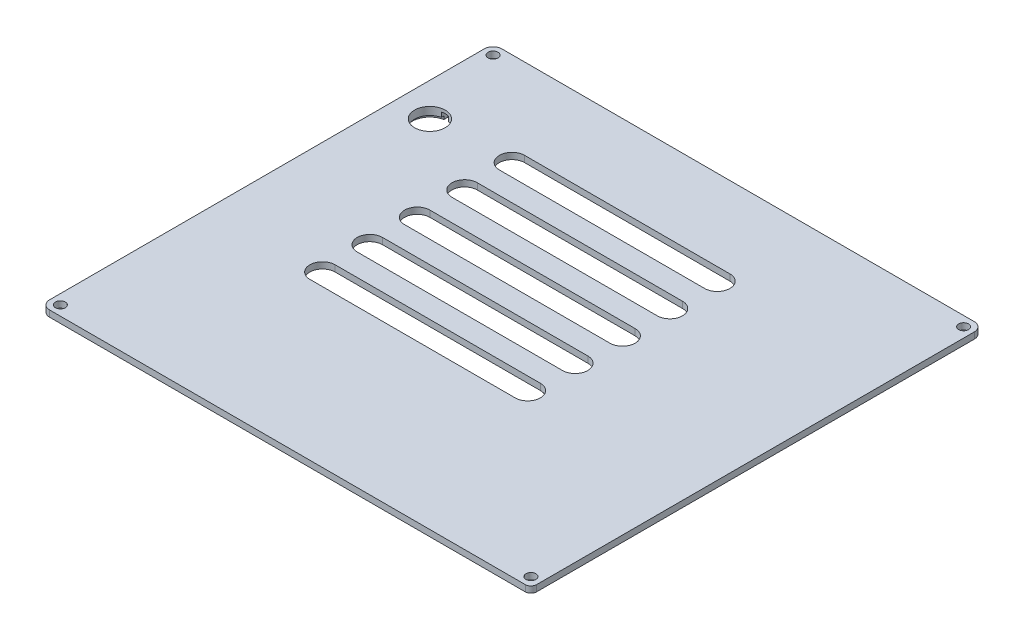
from build123d import *

# Parameters (mm, degrees)
SKETCH1_W           = 156
SKETCH1_H           = 144
BOSS_EXTRUDE1_DEPTH = 2
SKETCH2_R           = 1.575
CUT_EXTRUDE1_DEPTH  = 5
SKETCH3_R           = 4.85
CUT_EXTRUDE2_DEPTH  = 50
SKETCH4_W           = 156
SKETCH4_H           = 144
SKETCH4_W_2         = 155.6
SKETCH4_H_2         = 143.6
CUT_EXTRUDE3_DEPTH  = 50
FILLET1_R           = 3
FILLET2_R           = 2
SKETCH5_R           = 9
SKETCH5_R_2         = 4.85
BOSS_EXTRUDE2_DEPTH = 0.5
SKETCH6_R           = 9
SKETCH6_R_2         = 5.65
BOSS_EXTRUDE3_DEPTH = 1
SKETCH7_W           = 2.2
SKETCH7_H           = 2.3
CUT_EXTRUDE4_DEPTH  = 2.5
CUT_EXTRUDE5_DEPTH  = 10


with BuildPart() as part:
    # Sketch1 → Boss-Extrude1 (new body)
    with BuildSketch(Plane(origin=(0, 0, 0), x_dir=(1, 0, 0), z_dir=(0, 1, 0))):
        with Locations((78, -72)):
            Rectangle(SKETCH1_W, SKETCH1_H)
    extrude(amount=BOSS_EXTRUDE1_DEPTH)

    # Sketch2 → Cut-Extrude1 (cut)
    with BuildSketch(Plane(origin=(0, 2, 0), x_dir=(1, 0, 0), z_dir=(0, 1, 0))):
        with Locations((3.5, -3.5)):
            Circle(SKETCH2_R)
        with Locations((152.5, -3.5)):
            Circle(SKETCH2_R)
        with Locations((152.5, -140.5)):
            Circle(SKETCH2_R)
        with Locations((3.5, -140.5)):
            Circle(SKETCH2_R)
    extrude(amount=-CUT_EXTRUDE1_DEPTH, mode=Mode.SUBTRACT)

    # Sketch3 → Cut-Extrude2 (cut)
    with BuildSketch(Plane(origin=(0, 2, 0), x_dir=(1, 0, 0), z_dir=(0, 1, 0))):
        with Locations((11, -31)):
            Circle(SKETCH3_R)
        with BuildLine():
            Line((36, -26), (101, -26))
            ThreePointArc((101, -26), (105, -30), (101, -34))
            Line((101, -34), (36, -34))
            ThreePointArc((36, -34), (32, -30), (36, -26))
        make_face()
        with BuildLine():
            Line((36, -41), (101, -41))
            ThreePointArc((101, -41), (105, -45), (101, -49))
            Line((101, -49), (36, -49))
            ThreePointArc((36, -49), (32, -45), (36, -41))
        make_face()
        with BuildLine():
            Line((36, -56), (101, -56))
            ThreePointArc((101, -56), (105, -60), (101, -64))
            Line((101, -64), (36, -64))
            ThreePointArc((36, -64), (32, -60), (36, -56))
        make_face()
        with BuildLine():
            Line((36, -71), (101, -71))
            ThreePointArc((101, -71), (105, -75), (101, -79))
            Line((101, -79), (36, -79))
            ThreePointArc((36, -79), (32, -75), (36, -71))
        make_face()
        with BuildLine():
            Line((36, -86), (101, -86))
            ThreePointArc((101, -86), (105, -90), (101, -94))
            Line((101, -94), (36, -94))
            ThreePointArc((36, -94), (32, -90), (36, -86))
        make_face()
    extrude(amount=-CUT_EXTRUDE2_DEPTH, mode=Mode.SUBTRACT)

    # Sketch4 → Cut-Extrude3 (cut)
    with BuildSketch(Plane(origin=(0, 2, 0), x_dir=(1, 0, 0), z_dir=(0, 1, 0))):
        with Locations((78, -72)):
            Rectangle(SKETCH4_W, SKETCH4_H)
        with Locations((78, -72)):
            Rectangle(SKETCH4_W_2, SKETCH4_H_2, mode=Mode.SUBTRACT)
    extrude(amount=-CUT_EXTRUDE3_DEPTH, mode=Mode.SUBTRACT)

    # Fillet1
    fillet1_edges = [part.edges().sort_by_distance(p)[0] for p in [
        (0.2, 1, 0.2),
        (155.8, 1, 0.2),
        (0.2, 1, 143.8),
    ]]
    fillet(fillet1_edges, radius=FILLET1_R)

    # Fillet2
    fillet2_edges = [part.edges().sort_by_distance(p)[0] for p in [
        (155.8, 1, 143.8),
    ]]
    fillet(fillet2_edges, radius=FILLET2_R)

    # Sketch5 → Boss-Extrude2 (add)
    with BuildSketch(Plane.XZ):
        with Locations((11, 31)):
            Circle(SKETCH5_R)
        with Locations((11, 31)):
            Circle(SKETCH5_R_2, mode=Mode.SUBTRACT)
    extrude(amount=BOSS_EXTRUDE2_DEPTH)

    # Sketch6 → Boss-Extrude3 (add)
    with BuildSketch(Plane.XZ.offset(0.5)):
        with Locations((11, 31)):
            Circle(SKETCH6_R)
        with Locations((11, 31)):
            Circle(SKETCH6_R_2, mode=Mode.SUBTRACT)
    extrude(amount=BOSS_EXTRUDE3_DEPTH)

    # Sketch7 → Cut-Extrude4 (cut)
    with BuildSketch(Plane.XZ.offset(1.5)):
        with Locations((11, 25.35)):
            Rectangle(SKETCH7_W, SKETCH7_H)
    extrude(amount=-CUT_EXTRUDE4_DEPTH, mode=Mode.SUBTRACT)

    # Sketch8 → Cut-Extrude5 (cut)
    with BuildSketch(Plane(origin=(0, 2, 0), x_dir=(1, 0, 0), z_dir=(0, 1, 0))):
        with BuildLine():
            Line((3.2, -143.8), (153.8, -143.8))
            ThreePointArc((153.8, -143.8), (155.214213562, -143.214213562), (155.8, -141.8))
            Line((155.8, -141.8), (155.8, -3.2))
            ThreePointArc((155.8, -3.2), (154.921320344, -1.078679656), (152.8, -0.2))
            Line((152.8, -0.2), (3.2, -0.2))
            ThreePointArc((3.2, -0.2), (1.078679656, -1.078679656), (0.2, -3.2))
            Line((0.2, -3.2), (0.2, -140.8))
            ThreePointArc((0.2, -140.8), (1.078679656, -142.921320344), (3.2, -143.8))
        make_face()
        with BuildLine():
            Line((3.2, -143.6), (153.8, -143.6))
            ThreePointArc((153.8, -143.6), (155.072792206, -143.072792206), (155.6, -141.8))
            Line((155.6, -141.8), (155.6, -3.2))
            ThreePointArc((155.6, -3.2), (154.779898987, -1.220101013), (152.8, -0.4))
            Line((152.8, -0.4), (3.2, -0.4))
            ThreePointArc((3.2, -0.4), (1.220101013, -1.220101013), (0.4, -3.2))
            Line((0.4, -3.2), (0.4, -140.8))
            ThreePointArc((0.4, -140.8), (1.220101013, -142.779898987), (3.2, -143.6))
        make_face(mode=Mode.SUBTRACT)
    extrude(amount=-CUT_EXTRUDE5_DEPTH, mode=Mode.SUBTRACT)


solid = part.part
